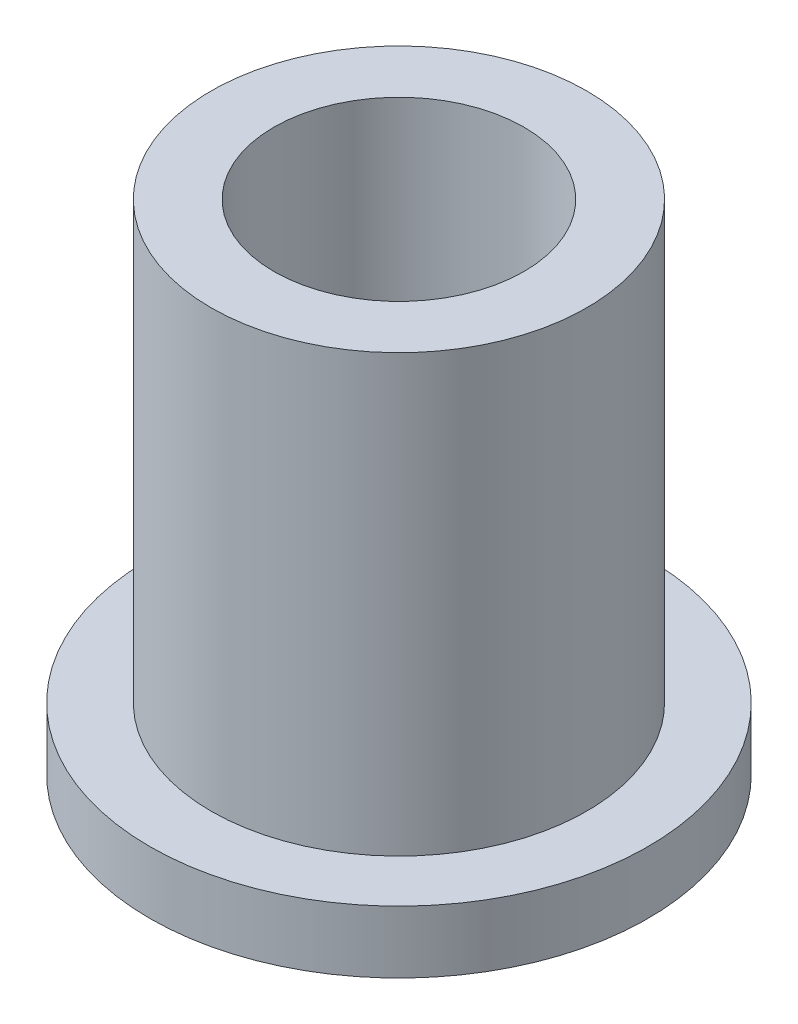
from build123d import *

# Parameters (mm, degrees)
SKETCH2_R           = 4.7879
SKETCH2_R_2         = 3.1877
BOSS_EXTRUDE1_DEPTH = 12.7
SKETCH3_R           = 6.35
SKETCH3_R_2         = 4.7879
BOSS_EXTRUDE2_DEPTH = 1.5875


with BuildPart() as part:
    # Sketch2 → Boss-Extrude1 (new body)
    with BuildSketch(Plane(origin=(0, 0, 0), x_dir=(1, 0, 0), z_dir=(0, 1, 0))):
        Circle(SKETCH2_R)
        Circle(SKETCH2_R_2, mode=Mode.SUBTRACT)
    extrude(amount=BOSS_EXTRUDE1_DEPTH)

    # Sketch3 → Boss-Extrude2 (add)
    with BuildSketch(Plane(origin=(0, 0, 0), x_dir=(1, 0, 0), z_dir=(0, 1, 0))):
        Circle(SKETCH3_R)
        Circle(SKETCH3_R_2, mode=Mode.SUBTRACT)
    extrude(amount=BOSS_EXTRUDE2_DEPTH)


solid = part.part
